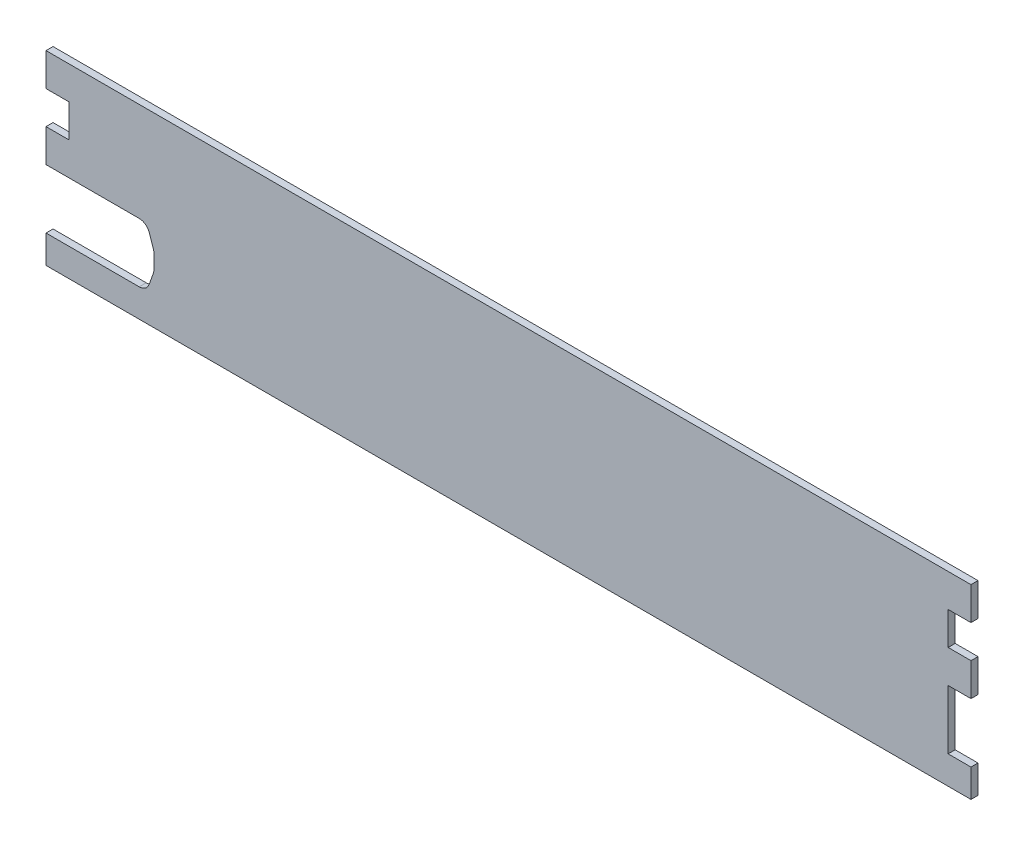
from build123d import *

# Parameters (mm, degrees)
BOSS_EXTRU_1_DEPTH = 2


with BuildPart() as part:
    # Esquisse1 → Boss.-Extru.1 (new body)
    with BuildSketch(Plane.XY):
        with BuildLine():
            Line((-875.748326024, -75.185778964), (-878.248326024, -75.185778964))
            Line((-878.248326024, -75.185778964), (-878.248326024, -67.185778964))
            Line((-878.248326024, -67.185778964), (-875.748326024, -67.185778964))
            Line((-875.748326024, -67.185778964), (-851.698326024, -67.185778964))
            ThreePointArc((-851.698326024, -67.185778964), (-849.970412013, -66.63818863), (-848.873290676, -65.195321078))
            Line((-848.873290676, -65.195321078), (-847.673290676, -61.837321078))
            ThreePointArc((-847.673290676, -61.837321078), (-847.542390805, -61.340074755), (-847.498326024, -60.827778964))
            Line((-847.498326024, -60.827778964), (-847.498326024, -56.827778964))
            ThreePointArc((-847.498326024, -56.827778964), (-847.538821892, -56.336520083), (-847.659216217, -55.858523838))
            Line((-847.659216217, -55.858523838), (-848.859216217, -52.343523838))
            ThreePointArc((-848.859216217, -52.343523838), (-849.95301307, -50.872721036), (-851.698326024, -50.312778964))
            Line((-851.698326024, -50.312778964), (-875.748326024, -50.312778964))
            Line((-875.748326024, -50.312778964), (-878.248326024, -50.312778964))
            Line((-878.248326024, -50.312778964), (-878.248326024, -40.935651694))
            Line((-878.248326024, -40.935651694), (-875.748326024, -40.935651694))
            Line((-875.748326024, -40.935651694), (-871.748326024, -40.935651694))
            Line((-871.748326024, -40.935651694), (-871.748326024, -31.558524425))
            Line((-871.748326024, -31.558524425), (-875.748326024, -31.558524425))
            Line((-875.748326024, -31.558524425), (-878.248326024, -31.558524425))
            Line((-878.248326024, -31.558524425), (-878.248326024, -22.181397155))
            Line((-878.248326024, -22.181397155), (-875.748326024, -22.181397155))
            Line((-875.748326024, -22.181397155), (-617.248326024, -22.181397155))
            Line((-617.248326024, -22.181397155), (-614.748326024, -22.181397155))
            Line((-614.748326024, -22.181397155), (-614.748326024, -31.558524425))
            Line((-614.748326024, -31.558524425), (-617.248326024, -31.558524425))
            Line((-617.248326024, -31.558524425), (-621.248326024, -31.558524425))
            Line((-621.248326024, -31.558524425), (-621.248326024, -40.935651694))
            Line((-621.248326024, -40.935651694), (-617.248326024, -40.935651694))
            Line((-617.248326024, -40.935651694), (-614.748326024, -40.935651694))
            Line((-614.748326024, -40.935651694), (-614.748326024, -50.312778964))
            Line((-614.748326024, -50.312778964), (-621.248326024, -50.312778964))
            Line((-621.248326024, -50.312778964), (-621.248326024, -67.185778964))
            Line((-621.248326024, -67.185778964), (-617.248326024, -67.185778964))
            Line((-617.248326024, -67.185778964), (-614.748326024, -67.185778964))
            Line((-614.748326024, -67.185778964), (-614.748326024, -75.185778964))
            Line((-614.748326024, -75.185778964), (-617.248326024, -75.185778964))
            Line((-617.248326024, -75.185778964), (-875.748326024, -75.185778964))
        make_face()
    extrude(amount=-BOSS_EXTRU_1_DEPTH)


solid = part.part
